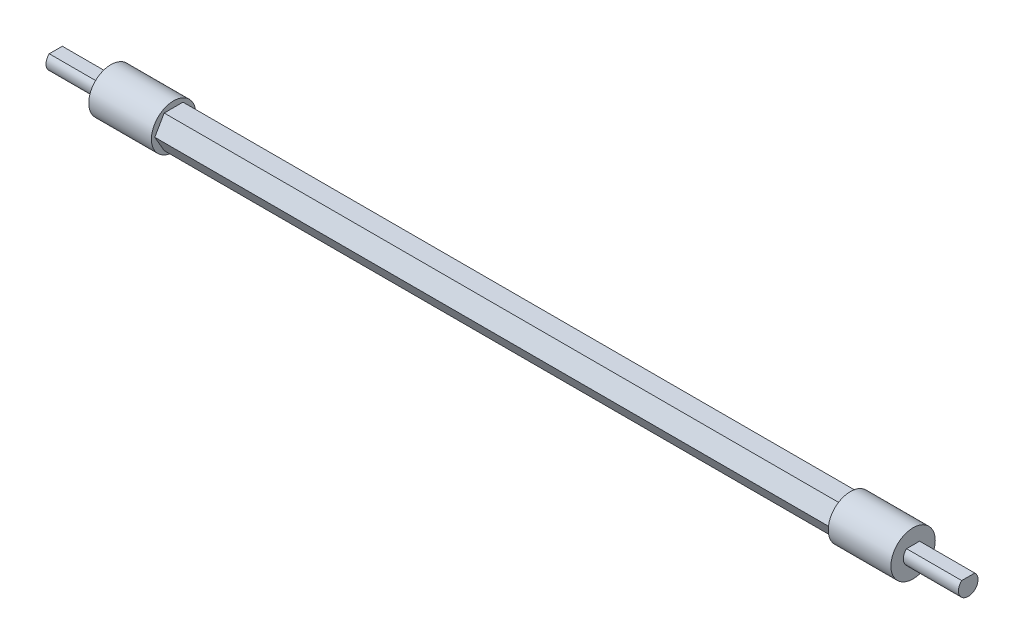
from build123d import *

# Parameters (mm, degrees)
BOSS_EXTRUDE1_DEPTH = 67.5
BOSS_EXTRUDE2_START = 67.5
SKETCH1_3_R         = 4.425
BOSS_EXTRUDE2_DEPTH = 12.5
BOSS_EXTRUDE4_DEPTH = 11


with BuildPart() as part:
    # Sketch1 → Boss-Extrude1 (new, symmetric)
    with BuildSketch(Plane(origin=(0, 0, 0), x_dir=(0, 0, -1), z_dir=(1, 0, 0))):
        Polygon((1.875, -3.247595264), (3.75, 0), (1.875, 3.247595264), (-1.875, 3.247595264), (-3.75, 0), (-1.875, -3.247595264), align=None)
    extrude(amount=BOSS_EXTRUDE1_DEPTH, both=True)

    # Sketch1_3 → Boss-Extrude2 (add)
    with BuildSketch(Plane(origin=(0, 0, 0), x_dir=(0, 0, -1), z_dir=(1, 0, 0)).offset(BOSS_EXTRUDE2_START)):
        Circle(SKETCH1_3_R)
    boss_extrude2 = extrude(amount=BOSS_EXTRUDE2_DEPTH)

    # Sketch4 → Boss-Extrude4 (add)
    with BuildSketch(Plane(origin=(80, 0, 0), x_dir=(0, 0, -1), z_dir=(1, 0, 0))):
        with BuildLine():
            Line((1.303840481, 1.45), (-1.303840481, 1.45))
            ThreePointArc((-1.303840481, 1.45), (-0.793728878, -1.78114976), (1.95, 0))
            ThreePointArc((1.95, 0), (1.78114976, 0.793728878), (1.303840481, 1.45))
        make_face()
    boss_extrude4 = extrude(amount=BOSS_EXTRUDE4_DEPTH)

    # Mirror2: Boss-Extrude2, Boss-Extrude4 across plane
    add(boss_extrude2.mirror(Plane(origin=(0, 0, 0), x_dir=(0, 0, 1), z_dir=(1, 0, 0))))
    add(boss_extrude4.mirror(Plane(origin=(0, 0, 0), x_dir=(0, 0, 1), z_dir=(1, 0, 0))))


solid = part.part
